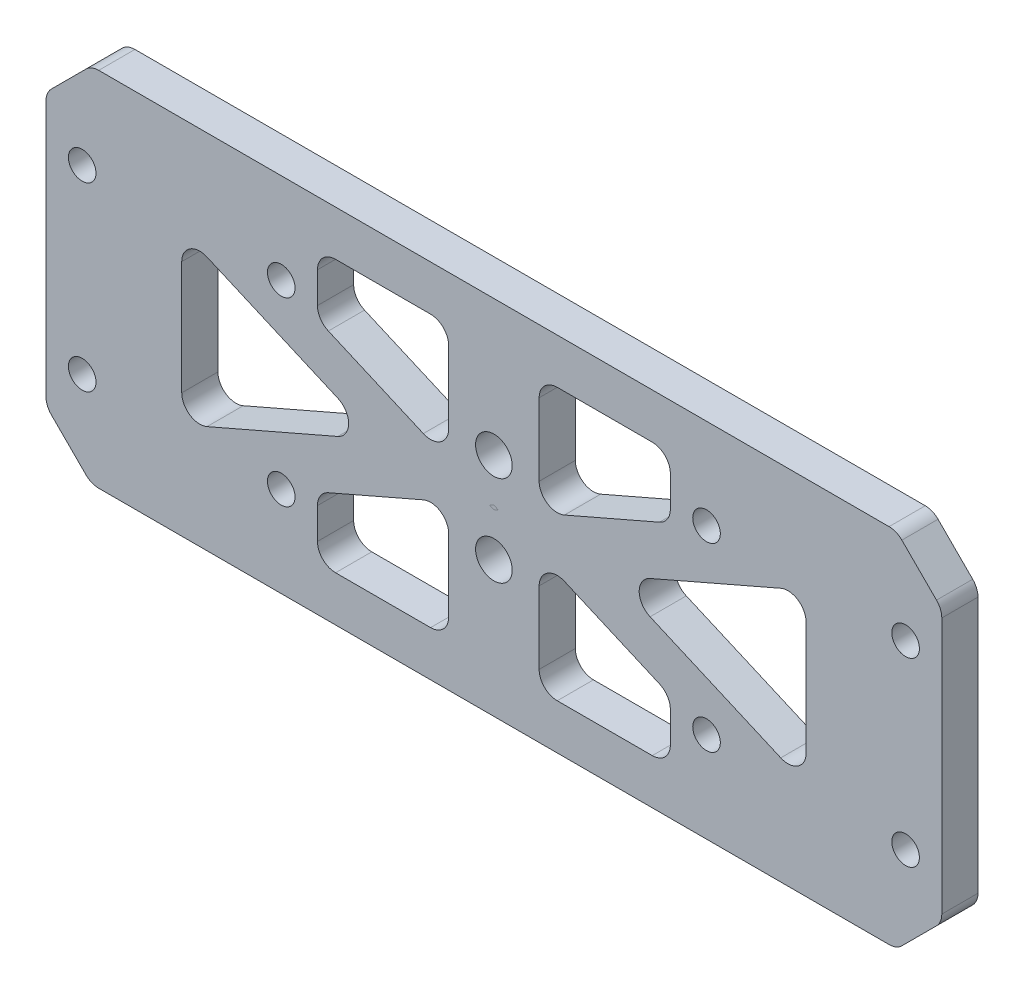
from build123d import *

# Parameters (mm, degrees)
SKETCH_1_W          = 99
SKETCH_1_H          = 40
EXTRUDE_1_DEPTH     = 4
CHAMFER_1_SIZE      = 5
SKETCH_3_R          = 1.525
CUT_EXTRUDE_1_DEPTH = 10
CUT_EXTRUDE_2_DEPTH = 10
SKETCH_5_W          = 10
SKETCH_5_H          = 30
EXTRUDE_2_DEPTH     = 4
FILLET_2_R          = 2
FILLET_3_R          = 2
EXTRUDE_3_DEPTH     = 4
FILLET_4_R          = 2
SKETCH_7_R          = 1.525
CUT_EXTRUDE_3_DEPTH = 54.537370126
SKETCH_8_R          = 2.025
CUT_EXTRUDE_4_DEPTH = 4


with BuildPart() as part:
    # 草图1 → 凸台-拉伸1 (new body)
    with BuildSketch(Plane.XY):
        Rectangle(SKETCH_1_W, SKETCH_1_H)
    extrude(amount=EXTRUDE_1_DEPTH)

    # 倒角1
    chamfer_1_edges = [part.edges().sort_by_distance(p)[0] for p in [
        (49.5, -20, 2),
        (-49.5, -20, 2),
        (-49.5, 20, 2),
        (49.5, 20, 2),
    ]]
    chamfer(chamfer_1_edges, length=CHAMFER_1_SIZE)

    # 草图3 → 切除-拉伸1 (cut)
    with BuildSketch(Plane.XY.offset(4)):
        with Locations((-45.5, 10)):
            Circle(SKETCH_3_R)
        with Locations((-45.5, -10)):
            Circle(SKETCH_3_R)
        with Locations(Location((45.5, -10, 0), (0, 0, 180))):
            Circle(SKETCH_3_R)
        with Locations(Location((45.5, 10, 0), (0, 0, 180))):
            Circle(SKETCH_3_R)
    extrude(amount=-CUT_EXTRUDE_1_DEPTH, mode=Mode.SUBTRACT)

    # 草图4 → 切除-拉伸2 (cut)
    with BuildSketch(Plane.XY.offset(4)):
        Polygon((35, 15), (-35, 15), (-0.5, 0), (0, 0.217391304), (0.5, 0), align=None)
        Polygon((0, -0.217391304), (-0.5, 0), (-35, -15), (35, -15), (0.5, 0), align=None)
        Polygon((-34.5, -9.33046252), (-13.039936204, 0), (-34.5, 9.33046252), align=None)
        Polygon((34.5, -9.33046252), (13.039936204, 0), (34.5, 9.33046252), align=None)
    extrude(amount=-CUT_EXTRUDE_2_DEPTH, mode=Mode.SUBTRACT)


with BuildPart() as cut_extrude_2_piece_1:
    # of the separate pieces the step leaves, piece 1, a body of its own (cut_extrude_2_pieces)
    add(part.part.solids().sort_by_distance((-44.5, -20, 0))[0])

    # 草图5 → 凸台-拉伸2 (add)
    with BuildSketch(Plane.XY.offset(4)):
        Rectangle(SKETCH_5_W, SKETCH_5_H)
    extrude(amount=-EXTRUDE_2_DEPTH)

    # 圆角2
    fillet_2_edges = [cut_extrude_2_piece_1.edges().sort_by_distance(p)[0] for p in [
        (34.5, -9.33046252, 2),
        (-5, -1.956521739, 2),
        (-5, -15, 2),
        (5, -1.956521739, 2),
        (-5, 15, 2),
        (-5, 1.956521739, 2),
        (5, -15, 2),
        (5, 1.956521739, 2),
        (5, 15, 2),
        (-35, 15, 2),
        (35, 15, 2),
        (35, -15, 2),
        (-35, -15, 2),
        (-34.5, -9.33046252, 2),
        (-34.5, 9.33046252, 2),
        (-13.039936204, 0, 2),
        (13.039936204, 0, 2),
        (34.5, 9.33046252, 2),
    ]]
    fillet(fillet_2_edges, radius=FILLET_2_R)

    # 圆角3
    fillet_3_edges = [cut_extrude_2_piece_1.edges().sort_by_distance(p)[0] for p in [
        (49.5, -15, 2),
        (49.5, 15, 2),
        (44.5, 20, 2),
        (-44.5, 20, 2),
        (-49.5, -15, 2),
        (-49.5, 15, 2),
        (44.5, -20, 2),
        (-44.5, -20, 2),
    ]]
    fillet(fillet_3_edges, radius=FILLET_3_R)

    # 草图6 → 凸台-拉伸3 (add)
    with BuildSketch(Plane(origin=(0, 0, 0), x_dir=(-1, 0, 0), z_dir=(0, 0, -1))):
        Polygon((-19.5, 8.260869565), (-19.5, 15), (-35, 15), align=None)
        Polygon((35, 15), (19.5, 8.260869565), (19.5, 15), align=None)
        Polygon((19.5, -8.260869565), (19.5, -15), (35, -15), align=None)
        Polygon((-35, -15), (-19.5, -8.260869565), (-19.5, -15), align=None)
    extrude(amount=-EXTRUDE_3_DEPTH)

    # 圆角4
    fillet_4_edges = [cut_extrude_2_piece_1.edges().sort_by_distance(p)[0] for p in [
        (19.5, 8.260869565, 2),
        (19.5, 15, 2),
        (-19.5, 15, 2),
        (-19.5, 8.260869565, 2),
        (-19.5, -8.260869565, 2),
        (-19.5, -15, 2),
        (19.5, -15, 2),
        (19.5, -8.260869565, 2),
    ]]
    fillet(fillet_4_edges, radius=FILLET_4_R)

    # 草图7 → 切除-拉伸3 (cut, through all)
    with BuildSketch(Plane(origin=(0, 0, 0), x_dir=(-1, 0, 0), z_dir=(0, 0, -1))):
        with Locations((-23.5, 10)):
            Circle(SKETCH_7_R)
        with Locations((-23.5, -10)):
            Circle(SKETCH_7_R)
        with Locations(Location((23.5, -10, 0), (0, 0, 180))):
            Circle(SKETCH_7_R)
        with Locations(Location((23.5, 10, 0), (0, 0, 180))):
            Circle(SKETCH_7_R)
    extrude(amount=-CUT_EXTRUDE_3_DEPTH, mode=Mode.SUBTRACT)

    # 草图8 → 切除-拉伸4 (cut)
    with BuildSketch(Plane.XY.offset(4)):
        with Locations((0, 5)):
            Circle(SKETCH_8_R)
        with Locations((0, -5)):
            Circle(SKETCH_8_R)
    extrude(amount=-CUT_EXTRUDE_4_DEPTH, mode=Mode.SUBTRACT)


with BuildPart() as cut_extrude_2_piece_2:
    # of the separate pieces the step leaves, piece 2, a body of its own (cut_extrude_2_pieces)
    add(part.part.solids().sort_by_distance((0, -0.217391304, 0))[0])


solid = Compound([cut_extrude_2_piece_1.part, cut_extrude_2_piece_2.part])
